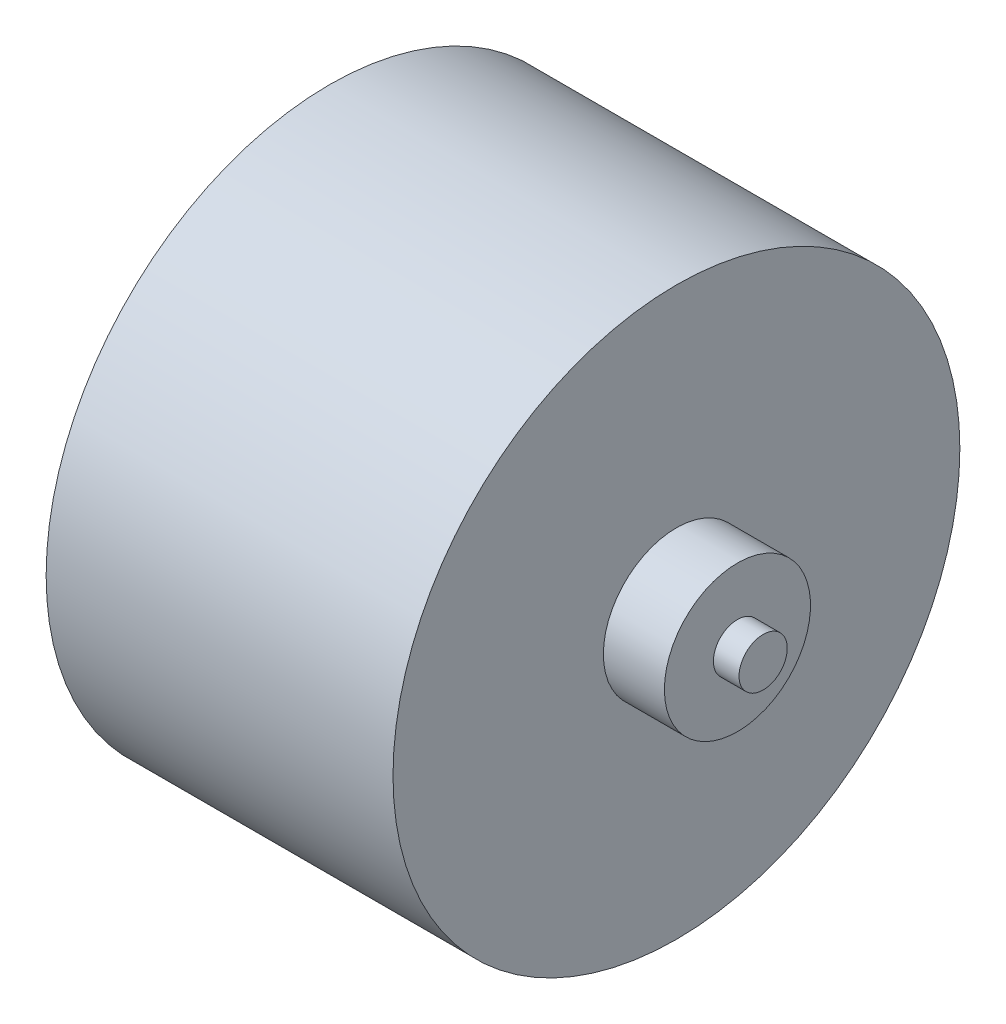
from build123d import *

# Parameters (mm, degrees)
SKETCH_1_W          = 6.6
SKETCH_1_H          = 1.5
SKETCH_1_W_2        = 1.6
SKETCH_2_R          = 2
CUT_EXTRUDE_1_DEPTH = 5


with BuildPart() as part:
    # 草图1 → 旋转2 (revolve)
    with BuildSketch(Plane.XY):
        with Locations((-25.652830189, 0.75)):
            Rectangle(SKETCH_1_W, SKETCH_1_H)
        Polygon((-22.352830189, 1.5), (-22.352830189, 0), (-19.352830189, 0), (-19.352830189, 4.55), (-22.352830189, 4.55), align=None)
        Polygon((-19.352830189, 4.55), (-19.352830189, 0), (2.247169811, 0), (2.247169811, 4.55), (2.247169811, 17.65), (-19.352830189, 17.65), align=None)
        Polygon((2.247169811, 4.55), (2.247169811, 0), (6.047169811, 0), (6.047169811, 1.5), (6.047169811, 4.55), align=None)
        with Locations((6.847169811, 0.75)):
            Rectangle(SKETCH_1_W_2, SKETCH_1_H)
    revolve(axis=Axis((-28.952830189, 0, 0), (1, 0, 0)))

    # 草图2 → 切除-拉伸1 (cut)
    with BuildSketch(Plane.ZY.offset(19.352830189)):
        with Locations((0, 12.5)):
            Circle(SKETCH_2_R)
        with Locations((0, -12.5)):
            Circle(SKETCH_2_R)
        with Locations((-12.5, 0)):
            Circle(SKETCH_2_R)
        with Locations((12.5, 0)):
            Circle(SKETCH_2_R)
    extrude(amount=-CUT_EXTRUDE_1_DEPTH, mode=Mode.SUBTRACT)


solid = part.part
